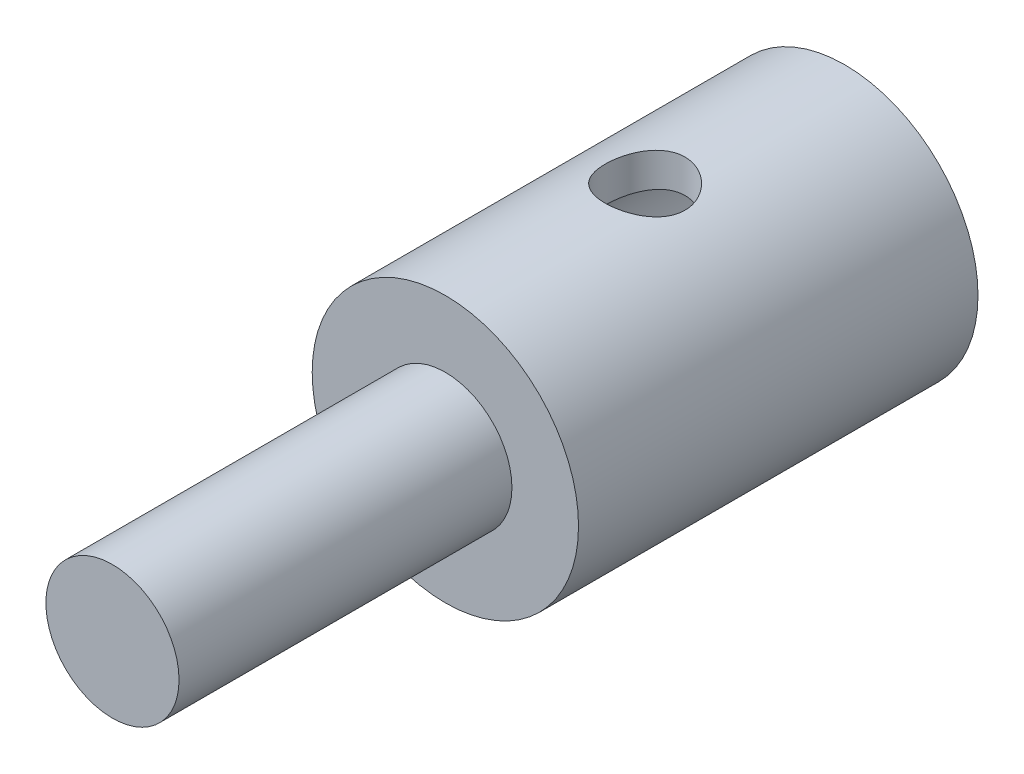
from build123d import *

# Parameters (mm, degrees)
ESQUISSE2_R                  = 0.6
ENL_V_MAT_EXTRU_1_DEPTH      = 3
ENL_V_MAT_EXTRU_1_DEPTH_BACK = 3


with BuildPart() as part:
    # Esquisse1 → Révolution1 (revolve)
    with BuildSketch(Plane(origin=(0, 0, 0), x_dir=(0, 0, -1), z_dir=(1, 0, 0))):
        Polygon((-5.5, 0), (-5.5, 1), (-0.5, 1), (-0.5, 2), (5.5, 2), (5.5, 1.5), (1.5, 1.5), (1.5, 0), align=None)
    revolve(axis=Axis((0, 0, 5.5), (0, 0, -1)))

    # Esquisse2 → Enlèv. mat.-Extru.1 (cut, two sides)
    with BuildSketch(Plane(origin=(0, 0, 0), x_dir=(1, 0, 0), z_dir=(0, 1, 0))) as enl_v_mat_extru_1_sk:
        with Locations((0, 2.5)):
            Circle(ESQUISSE2_R)
    extrude(amount=ENL_V_MAT_EXTRU_1_DEPTH, mode=Mode.SUBTRACT)
    extrude(enl_v_mat_extru_1_sk.sketch, amount=-ENL_V_MAT_EXTRU_1_DEPTH_BACK, mode=Mode.SUBTRACT)


solid = part.part
